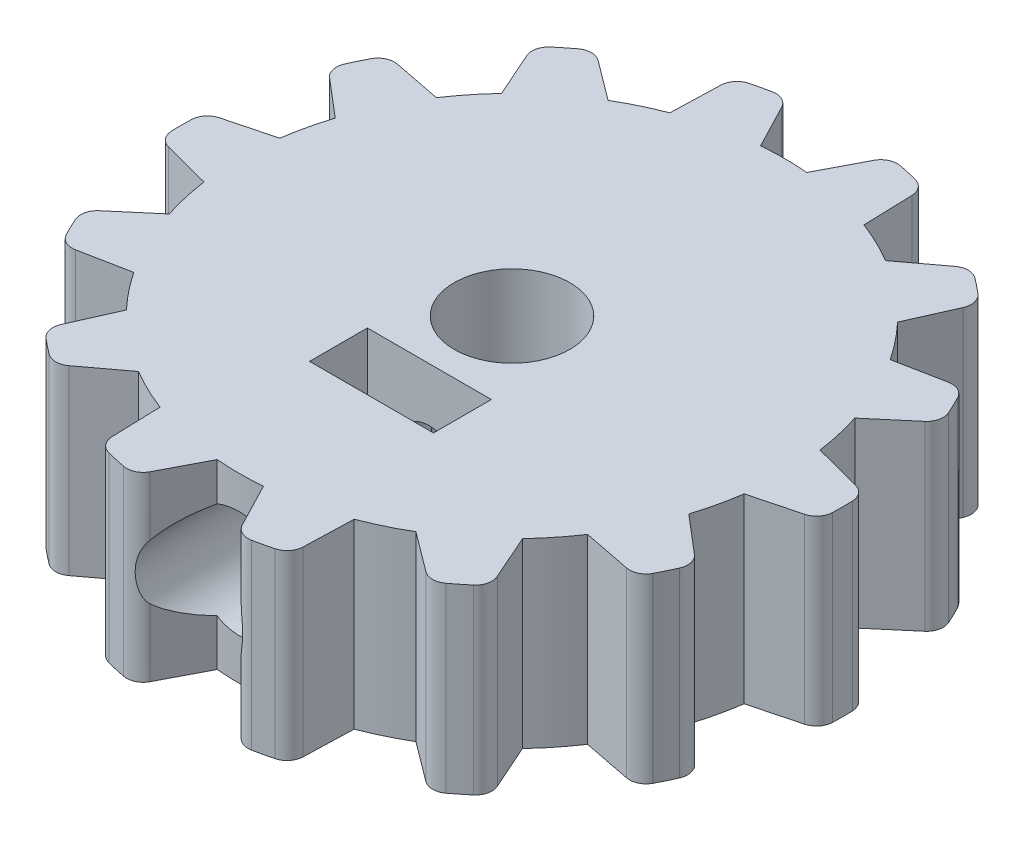
from build123d import *

# Parameters (mm, degrees)
SKETCH1_R                = 20
BOSS_EXTRUDE1_DEPTH      = 11
CUT_EXTRUDE1_DEPTH       = 11
FILLET1_R                = 1
CIRPATTERN1_COUNT        = 14
FILLET1_OF_CIRPATTERN1_R = 1
CUT_EXTRUDE2_REACH       = 13
SKETCH3_R                = 3.5
SKETCH4_W                = 7.5
SKETCH4_H                = 3.5
CUT_EXTRUDE3_DEPTH       = 9


with BuildPart() as part:
    # Sketch1 → Boss-Extrude1 (new body)
    with BuildSketch(Plane(origin=(0, 0, 0), x_dir=(1, 0, 0), z_dir=(0, 1, 0))):
        Circle(SKETCH1_R)
    extrude(amount=BOSS_EXTRUDE1_DEPTH)

    # Sketch2 → Cut-Extrude1 (cut)
    with BuildSketch(Plane(origin=(0, 11, 0), x_dir=(1, 0, 0), z_dir=(0, 1, 0))):
        with BuildLine():
            Line((-3.125, 19.754350787), (-1.399921321, 16.440505476))
            ThreePointArc((-1.399921321, 16.440505476), (0, 16.5), (1.399921321, 16.440505476))
            Line((1.399921321, 16.440505476), (3.125, 19.754350787))
            ThreePointArc((3.125, 19.754350787), (0, 20), (-3.125, 19.754350787))
        make_face()
    cut_extrude1 = extrude(amount=-CUT_EXTRUDE1_DEPTH, mode=Mode.SUBTRACT)

    # Fillet1
    fillet1_edges = [part.edges().sort_by_distance(p)[0] for p in [
        (-3.125, 5.5, -19.754350787),
        (3.125, 5.5, -19.754350787),
    ]]
    fillet(fillet1_edges, radius=FILLET1_R)

    # CirPattern1: Cut-Extrude1 ×14 about axis
    cirpattern1_axis = Axis((0, 0, 0), (0, 1, 0))
    for i in range(1, CIRPATTERN1_COUNT):
        add(cut_extrude1.rotate(cirpattern1_axis, i * 360 / CIRPATTERN1_COUNT), mode=Mode.SUBTRACT)

    # Fillet1 of CirPattern1
    fillet1_of_cirpattern1_edges = [part.edges().sort_by_distance(p)[0] for p in [
        (-11.386619295, 5.5, -16.44216838),
        (-5.755563871, 5.5, -19.153941749),
        (-17.392978991, 5.5, -9.873412875),
        (-13.49616773, 5.5, -14.75985964),
        (-19.954445887, 5.5, -1.349106861),
        (-18.56369005, 5.5, -7.442406312),
        (-18.56369005, 5.5, 7.442406312),
        (-19.954445887, 5.5, 1.349106861),
        (-13.49616773, 5.5, 14.75985964),
        (-17.392978991, 5.5, 9.873412875),
        (-5.755563871, 5.5, 19.153941749),
        (-11.386619295, 5.5, 16.44216838),
        (3.125, 5.5, 19.754350787),
        (-3.125, 5.5, 19.754350787),
        (11.386619295, 5.5, 16.44216838),
        (5.755563871, 5.5, 19.153941749),
        (17.392978991, 5.5, 9.873412875),
        (13.49616773, 5.5, 14.75985964),
        (19.954445887, 5.5, 1.349106861),
        (18.56369005, 5.5, 7.442406312),
        (18.56369005, 5.5, -7.442406312),
        (19.954445887, 5.5, -1.349106861),
        (13.49616773, 5.5, -14.75985964),
        (17.392978991, 5.5, -9.873412875),
        (5.755563871, 5.5, -19.153941749),
        (11.386619295, 5.5, -16.44216838),
    ]]
    fillet(fillet1_of_cirpattern1_edges, radius=FILLET1_OF_CIRPATTERN1_R)

    # Sketch3 → Cut-Extrude2 (cut, up to next)
    with BuildSketch(Plane(origin=(0, 11, 0), x_dir=(1, 0, 0), z_dir=(0, 1, 0)), mode=Mode.PRIVATE) as cut_extrude2_sk1:
        Circle(SKETCH3_R)
    cut_extrude2_tool1 = extrude(cut_extrude2_sk1.sketch, amount=-CUT_EXTRUDE2_REACH, mode=Mode.PRIVATE) & part.part
    add(cut_extrude2_tool1.solids().sort_by_distance((0, 11, 0))[0], mode=Mode.SUBTRACT)

    # Sketch4 → Cut-Extrude3 (cut)
    with BuildSketch(Plane(origin=(0, 11, 0), x_dir=(1, 0, 0), z_dir=(0, 1, 0))):
        with Locations((0, -6.75)):
            Rectangle(SKETCH4_W, SKETCH4_H)
    extrude(amount=-CUT_EXTRUDE3_DEPTH, mode=Mode.SUBTRACT)

    # Sketch6 → Cut-Revolve1 (revolve, cut)
    with BuildSketch(Plane(origin=(0, 0, 0), x_dir=(0, 0, -1), z_dir=(1, 0, 0))):
        Polygon((0, 5.75), (0, 7.75), (-10, 7.75), (-10, 9), (-25, 9), (-25, 5.75), align=None)
    revolve(axis=Axis((0, 5.75, 0), (0, 0, 1)), mode=Mode.SUBTRACT)


solid = part.part
